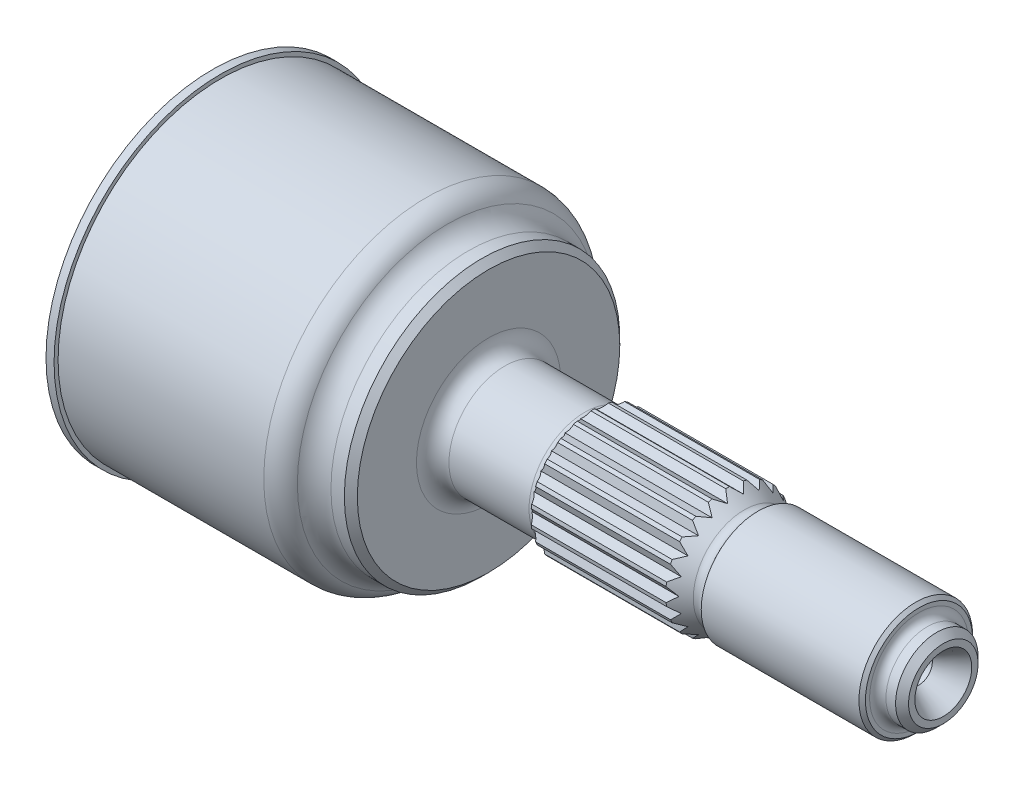
from build123d import *

# Parameters (mm, degrees)
SKETCH2_R          = 18.2245
CENTERPOCKET_DEPTH = 43.942
SKETCH4_R          = 4.7625
HOLES_DEPTH        = 41.275
EXTRUDE3_DEPTH     = 43.942
EXTRUDE4_REACH     = 88.12


with BuildPart() as part:
    # Sketch1 → ProfileRevolve (revolve)
    with BuildSketch(Plane(origin=(0, 0, 0), x_dir=(1, 0, 0), z_dir=(0, 1, 0))):
        with BuildLine():
            Line((0, 0), (0, 32.5374))
            Line((0, 32.5374), (1.5748, 32.5374))
            Line((1.5748, 32.5374), (1.5748, 31.75))
            Line((1.5748, 31.75), (41.783, 31.75))
            ThreePointArc((41.783, 31.75), (44.184517614, 31.102958473), (45.9359, 29.337))
            ThreePointArc((45.9359, 29.337), (47.687282386, 27.571041527), (50.0888, 26.924))
            Line((50.0888, 26.924), (52.705, 26.924))
            Line((52.705, 26.924), (53.975, 25.654))
            Line((53.975, 25.654), (53.975, 14.097))
            ThreePointArc((53.975, 14.097), (54.90493597, 11.85193597), (57.15, 10.922))
            Line((57.15, 10.922), (72.7964, 10.922))
            ThreePointArc((72.7964, 10.922), (73.768510133, 11.251120958), (74.340742977, 12.1031))
            Line((74.340742977, 12.1031), (100.711, 12.1031))
            Line((100.711, 12.1031), (103.979668616, 9.980401781))
            ThreePointArc((103.979668616, 9.980401781), (105.152184528, 9.750803676), (106.156907204, 10.397364731))
            Line((106.156907204, 10.397364731), (106.663571855, 11.1125))
            Line((106.663571855, 11.1125), (137.4902, 11.1125))
            Line((137.4902, 11.1125), (138.1252, 10.4775))
            Line((138.1252, 10.4775), (138.1252, 9.6647))
            ThreePointArc((138.1252, 9.6647), (138.593887729, 8.533187729), (139.7254, 8.0645))
            Line((139.7254, 8.0645), (141.605, 8.0645))
            Line((141.605, 8.0645), (142.875, 6.7945))
            Line((142.875, 6.7945), (142.875, 5.5626))
            Line((142.875, 5.5626), (138.1252, 2.60985))
            Line((138.1252, 2.60985), (134.3152, 2.60985))
            Line((134.3152, 2.60985), (132.554833947, 0))
            Line((132.554833947, 0), (0, 0))
        make_face()
    revolve(axis=Axis((-31.288090642, 0, 0), (1, 0, 0)))

    # Sketch2 → CenterPocket (cut)
    with BuildSketch(Plane.ZY):
        Circle(SKETCH2_R)
    extrude(amount=-CENTERPOCKET_DEPTH, mode=Mode.SUBTRACT)

    # Sketch4 → Holes (cut)
    with BuildSketch(Plane.ZY):
        with Locations((0, 24.638)):
            Circle(SKETCH4_R)
        with Locations((21.337133898, -12.319)):
            Circle(SKETCH4_R)
        with Locations((-21.337133898, -12.319)):
            Circle(SKETCH4_R)
    extrude(amount=-HOLES_DEPTH, mode=Mode.SUBTRACT)

    # Sketch5 → Extrude3 (cut)
    with BuildSketch(Plane.ZY):
        with BuildLine():
            ThreePointArc((-9.942949006, -27.195361756), (0, -28.956), (9.942949006, -27.195361756))
            ThreePointArc((9.942949006, -27.195361756), (11.025002375, -26.528967148), (11.759053938, -25.491619775))
            ThreePointArc((11.759053938, -25.491619775), (0, -7.47395), (-11.759053938, -25.491619775))
            ThreePointArc((-11.759053938, -25.491619775), (-11.025002375, -26.528967148), (-9.942949006, -27.195361756))
        make_face()
        with BuildLine():
            ThreePointArc((-27.955917277, 2.562170453), (-6.472630567, 3.736975), (-16.19686334, 22.929449322))
            ThreePointArc((-16.19686334, 22.929449322), (-17.462258298, 22.812415708), (-18.580399643, 22.208527306))
            ThreePointArc((-18.580399643, 22.208527306), (-25.076631592, 14.478), (-28.523348649, 4.98683445))
            ThreePointArc((-28.523348649, 4.98683445), (-28.487260674, 3.71655144), (-27.955917277, 2.562170453))
        make_face()
        with BuildLine():
            ThreePointArc((16.19686334, 22.929449322), (6.472630567, 3.736975), (27.955917277, 2.562170453))
            ThreePointArc((27.955917277, 2.562170453), (28.487260674, 3.71655144), (28.523348649, 4.98683445))
            ThreePointArc((28.523348649, 4.98683445), (25.076631592, 14.478), (18.580399643, 22.208527306))
            ThreePointArc((18.580399643, 22.208527306), (17.462258298, 22.812415708), (16.19686334, 22.929449322))
        make_face()
    extrude(amount=-EXTRUDE3_DEPTH, mode=Mode.SUBTRACT)

    # Sketch6 → Cut-Revolve1 (revolve, cut)
    with BuildSketch(Plane.XY):
        with BuildLine():
            Line((43.922024716, 18.2245), (2.915575284, 18.2245))
            ThreePointArc((2.915575284, 18.2245), (-2.222563891, 9.748593837), (-4.0132, 0))
            Line((-4.0132, 0), (50.8508, 0))
            ThreePointArc((50.8508, 0), (49.060163891, 9.748593837), (43.922024716, 18.2245))
        make_face()
    revolve(axis=Axis((-21.439153355, 0, 0), (1, 0, 0)), mode=Mode.SUBTRACT)

    # Sketch7 → Extrude4 (cut, up to next)
    with BuildSketch(Plane(origin=(72.7964, 0, 0), x_dir=(0, 0, -1), z_dir=(1, 0, 0)), mode=Mode.PRIVATE) as extrude4_sk1:
        with BuildLine():
            Line((0.368569215, 12.097486778), (1.577126308, 10.969154412))
            Line((1.577126308, 10.969154412), (3.054616309, 11.711291509))
            ThreePointArc((3.054616309, 11.711291509), (1.722450719, 11.979907893), (0.368569215, 12.097486778))
        make_face()
    extrude4_tool1 = extrude(extrude4_sk1.sketch, amount=EXTRUDE4_REACH, mode=Mode.PRIVATE) & part.part
    # Sketch7 → Extrude4 (cut, up to next)
    with BuildSketch(Plane(origin=(72.7964, 0, 0), x_dir=(0, 0, -1), z_dir=(1, 0, 0)), mode=Mode.PRIVATE) as extrude4_sk2:
        with BuildLine():
            Line((3.761895454, 11.503615615), (4.60360953, 10.080498758))
            Line((4.60360953, 10.080498758), (6.230334986, 10.376317052))
            ThreePointArc((6.230334986, 10.376317052), (5.027809444, 11.009367003), (3.761895454, 11.503615615))
        make_face()
    extrude4_tool2 = extrude(extrude4_sk2.sketch, amount=EXTRUDE4_REACH, mode=Mode.PRIVATE) & part.part
    # Sketch7 → Extrude4 (cut, up to next)
    with BuildSketch(Plane(origin=(72.7964, 0, 0), x_dir=(0, 0, -1), z_dir=(1, 0, 0)), mode=Mode.PRIVATE) as extrude4_sk3:
        with BuildLine():
            Line((6.850455295, 9.977789929), (7.257135686, 8.375181045))
            Line((7.257135686, 8.375181045), (8.901308976, 8.200715098))
            ThreePointArc((8.901308976, 8.200715098), (7.925844949, 9.146912673), (6.850455295, 9.977789929))
        make_face()
    extrude4_tool3 = extrude(extrude4_sk3.sketch, amount=EXTRUDE4_REACH, mode=Mode.PRIVATE) & part.part
    # Sketch7 → Extrude4 (cut, up to next)
    with BuildSketch(Plane(origin=(72.7964, 0, 0), x_dir=(0, 0, -1), z_dir=(1, 0, 0)), mode=Mode.PRIVATE) as extrude4_sk4:
        with BuildLine():
            Line((9.38403199, 7.643623043), (9.322731869, 5.991355973))
            Line((9.322731869, 5.991355973), (10.851151851, 5.360739978))
            ThreePointArc((10.851151851, 5.360739978), (10.181775633, 6.543429878), (9.38403199, 7.643623043))
        make_face()
    extrude4_tool4 = extrude(extrude4_sk4.sketch, amount=EXTRUDE4_REACH, mode=Mode.PRIVATE) & part.part
    # Sketch7 → Extrude4 (cut, up to next)
    with BuildSketch(Plane(origin=(72.7964, 0, 0), x_dir=(0, 0, -1), z_dir=(1, 0, 0)), mode=Mode.PRIVATE) as extrude4_sk5:
        with BuildLine():
            Line((11.157370222, 4.690215277), (10.633055761, 3.122146872))
            Line((10.633055761, 3.122146872), (11.921898937, 2.086469586))
            ThreePointArc((11.921898937, 2.086469586), (11.612839409, 3.409837309), (11.157370222, 4.690215277))
        make_face()
    extrude4_tool5 = extrude(extrude4_sk5.sketch, amount=EXTRUDE4_REACH, mode=Mode.PRIVATE) & part.part
    # Sketch7 → Extrude4 (cut, up to next)
    with BuildSketch(Plane(origin=(72.7964, 0, 0), x_dir=(0, 0, -1), z_dir=(1, 0, 0)), mode=Mode.PRIVATE) as extrude4_sk6:
        with BuildLine():
            Line((12.026804674, 1.356834162), (11.081952712, 0))
            Line((11.081952712, 0), (12.026804674, -1.356834162))
            ThreePointArc((12.026804674, -1.356834162), (12.1031, 0), (12.026804674, 1.356834162))
        make_face()
    extrude4_tool6 = extrude(extrude4_sk6.sketch, amount=EXTRUDE4_REACH, mode=Mode.PRIVATE) & part.part
    # Sketch7 → Extrude4 (cut, up to next)
    with BuildSketch(Plane(origin=(72.7964, 0, 0), x_dir=(0, 0, -1), z_dir=(1, 0, 0)), mode=Mode.PRIVATE) as extrude4_sk7:
        with BuildLine():
            Line((11.921898937, -2.086469586), (10.633055761, -3.122146872))
            Line((10.633055761, -3.122146872), (11.157370222, -4.690215277))
            ThreePointArc((11.157370222, -4.690215277), (11.612839409, -3.409837309), (11.921898937, -2.086469586))
        make_face()
    extrude4_tool7 = extrude(extrude4_sk7.sketch, amount=EXTRUDE4_REACH, mode=Mode.PRIVATE) & part.part
    # Sketch7 → Extrude4 (cut, up to next)
    with BuildSketch(Plane(origin=(72.7964, 0, 0), x_dir=(0, 0, -1), z_dir=(1, 0, 0)), mode=Mode.PRIVATE) as extrude4_sk8:
        with BuildLine():
            Line((10.851151851, -5.360739978), (9.322731869, -5.991355973))
            Line((9.322731869, -5.991355973), (9.38403199, -7.643623043))
            ThreePointArc((9.38403199, -7.643623043), (10.181775633, -6.543429878), (10.851151851, -5.360739978))
        make_face()
    extrude4_tool8 = extrude(extrude4_sk8.sketch, amount=EXTRUDE4_REACH, mode=Mode.PRIVATE) & part.part
    # Sketch7 → Extrude4 (cut, up to next)
    with BuildSketch(Plane(origin=(72.7964, 0, 0), x_dir=(0, 0, -1), z_dir=(1, 0, 0)), mode=Mode.PRIVATE) as extrude4_sk9:
        with BuildLine():
            Line((8.901308976, -8.200715098), (7.257135686, -8.375181045))
            Line((7.257135686, -8.375181045), (6.850455295, -9.977789929))
            ThreePointArc((6.850455295, -9.977789929), (7.925844949, -9.146912673), (8.901308976, -8.200715098))
        make_face()
    extrude4_tool9 = extrude(extrude4_sk9.sketch, amount=EXTRUDE4_REACH, mode=Mode.PRIVATE) & part.part
    # Sketch7 → Extrude4 (cut, up to next)
    with BuildSketch(Plane(origin=(72.7964, 0, 0), x_dir=(0, 0, -1), z_dir=(1, 0, 0)), mode=Mode.PRIVATE) as extrude4_sk10:
        with BuildLine():
            Line((6.230334986, -10.376317052), (4.60360953, -10.080498758))
            Line((4.60360953, -10.080498758), (3.761895454, -11.503615615))
            ThreePointArc((3.761895454, -11.503615615), (5.027809444, -11.009367003), (6.230334986, -10.376317052))
        make_face()
    extrude4_tool10 = extrude(extrude4_sk10.sketch, amount=EXTRUDE4_REACH, mode=Mode.PRIVATE) & part.part
    # Sketch7 → Extrude4 (cut, up to next)
    with BuildSketch(Plane(origin=(72.7964, 0, 0), x_dir=(0, 0, -1), z_dir=(1, 0, 0)), mode=Mode.PRIVATE) as extrude4_sk11:
        with BuildLine():
            Line((3.054616309, -11.711291509), (1.577126308, -10.969154412))
            Line((1.577126308, -10.969154412), (0.368569215, -12.097486778))
            ThreePointArc((0.368569215, -12.097486778), (1.722450719, -11.979907893), (3.054616309, -11.711291509))
        make_face()
    extrude4_tool11 = extrude(extrude4_sk11.sketch, amount=EXTRUDE4_REACH, mode=Mode.PRIVATE) & part.part
    # Sketch7 → Extrude4 (cut, up to next)
    with BuildSketch(Plane(origin=(72.7964, 0, 0), x_dir=(0, 0, -1), z_dir=(1, 0, 0)), mode=Mode.PRIVATE) as extrude4_sk12:
        with BuildLine():
            Line((-0.368569215, -12.097486778), (-1.577126308, -10.969154412))
            Line((-1.577126308, -10.969154412), (-3.054616309, -11.711291509))
            ThreePointArc((-3.054616309, -11.711291509), (-1.722450719, -11.979907893), (-0.368569215, -12.097486778))
        make_face()
    extrude4_tool12 = extrude(extrude4_sk12.sketch, amount=EXTRUDE4_REACH, mode=Mode.PRIVATE) & part.part
    # Sketch7 → Extrude4 (cut, up to next)
    with BuildSketch(Plane(origin=(72.7964, 0, 0), x_dir=(0, 0, -1), z_dir=(1, 0, 0)), mode=Mode.PRIVATE) as extrude4_sk13:
        with BuildLine():
            Line((-3.761895454, -11.503615615), (-4.60360953, -10.080498758))
            Line((-4.60360953, -10.080498758), (-6.230334986, -10.376317052))
            ThreePointArc((-6.230334986, -10.376317052), (-5.027809444, -11.009367003), (-3.761895454, -11.503615615))
        make_face()
    extrude4_tool13 = extrude(extrude4_sk13.sketch, amount=EXTRUDE4_REACH, mode=Mode.PRIVATE) & part.part
    # Sketch7 → Extrude4 (cut, up to next)
    with BuildSketch(Plane(origin=(72.7964, 0, 0), x_dir=(0, 0, -1), z_dir=(1, 0, 0)), mode=Mode.PRIVATE) as extrude4_sk14:
        with BuildLine():
            Line((-6.850455295, -9.977789929), (-7.257135686, -8.375181045))
            Line((-7.257135686, -8.375181045), (-8.901308976, -8.200715098))
            ThreePointArc((-8.901308976, -8.200715098), (-7.925844949, -9.146912673), (-6.850455295, -9.977789929))
        make_face()
    extrude4_tool14 = extrude(extrude4_sk14.sketch, amount=EXTRUDE4_REACH, mode=Mode.PRIVATE) & part.part
    # Sketch7 → Extrude4 (cut, up to next)
    with BuildSketch(Plane(origin=(72.7964, 0, 0), x_dir=(0, 0, -1), z_dir=(1, 0, 0)), mode=Mode.PRIVATE) as extrude4_sk15:
        with BuildLine():
            Line((-9.38403199, -7.643623043), (-9.322731869, -5.991355973))
            Line((-9.322731869, -5.991355973), (-10.851151851, -5.360739978))
            ThreePointArc((-10.851151851, -5.360739978), (-10.181775633, -6.543429878), (-9.38403199, -7.643623043))
        make_face()
    extrude4_tool15 = extrude(extrude4_sk15.sketch, amount=EXTRUDE4_REACH, mode=Mode.PRIVATE) & part.part
    # Sketch7 → Extrude4 (cut, up to next)
    with BuildSketch(Plane(origin=(72.7964, 0, 0), x_dir=(0, 0, -1), z_dir=(1, 0, 0)), mode=Mode.PRIVATE) as extrude4_sk16:
        with BuildLine():
            Line((-11.157370222, -4.690215277), (-10.633055761, -3.122146872))
            Line((-10.633055761, -3.122146872), (-11.921898937, -2.086469586))
            ThreePointArc((-11.921898937, -2.086469586), (-11.612839409, -3.409837309), (-11.157370222, -4.690215277))
        make_face()
    extrude4_tool16 = extrude(extrude4_sk16.sketch, amount=EXTRUDE4_REACH, mode=Mode.PRIVATE) & part.part
    # Sketch7 → Extrude4 (cut, up to next)
    with BuildSketch(Plane(origin=(72.7964, 0, 0), x_dir=(0, 0, -1), z_dir=(1, 0, 0)), mode=Mode.PRIVATE) as extrude4_sk17:
        with BuildLine():
            Line((-12.026804674, -1.356834162), (-11.081952712, 0))
            Line((-11.081952712, 0), (-12.026804674, 1.356834162))
            ThreePointArc((-12.026804674, 1.356834162), (-12.1031, 0), (-12.026804674, -1.356834162))
        make_face()
    extrude4_tool17 = extrude(extrude4_sk17.sketch, amount=EXTRUDE4_REACH, mode=Mode.PRIVATE) & part.part
    # Sketch7 → Extrude4 (cut, up to next)
    with BuildSketch(Plane(origin=(72.7964, 0, 0), x_dir=(0, 0, -1), z_dir=(1, 0, 0)), mode=Mode.PRIVATE) as extrude4_sk18:
        with BuildLine():
            Line((-11.921898937, 2.086469586), (-10.633055761, 3.122146872))
            Line((-10.633055761, 3.122146872), (-11.157370222, 4.690215277))
            ThreePointArc((-11.157370222, 4.690215277), (-11.612839409, 3.409837309), (-11.921898937, 2.086469586))
        make_face()
    extrude4_tool18 = extrude(extrude4_sk18.sketch, amount=EXTRUDE4_REACH, mode=Mode.PRIVATE) & part.part
    # Sketch7 → Extrude4 (cut, up to next)
    with BuildSketch(Plane(origin=(72.7964, 0, 0), x_dir=(0, 0, -1), z_dir=(1, 0, 0)), mode=Mode.PRIVATE) as extrude4_sk19:
        with BuildLine():
            Line((-10.851151851, 5.360739978), (-9.322731869, 5.991355973))
            Line((-9.322731869, 5.991355973), (-9.38403199, 7.643623043))
            ThreePointArc((-9.38403199, 7.643623043), (-10.181775633, 6.543429878), (-10.851151851, 5.360739978))
        make_face()
    extrude4_tool19 = extrude(extrude4_sk19.sketch, amount=EXTRUDE4_REACH, mode=Mode.PRIVATE) & part.part
    # Sketch7 → Extrude4 (cut, up to next)
    with BuildSketch(Plane(origin=(72.7964, 0, 0), x_dir=(0, 0, -1), z_dir=(1, 0, 0)), mode=Mode.PRIVATE) as extrude4_sk20:
        with BuildLine():
            Line((-8.901308976, 8.200715098), (-7.257135686, 8.375181045))
            Line((-7.257135686, 8.375181045), (-6.850455295, 9.977789929))
            ThreePointArc((-6.850455295, 9.977789929), (-7.925844949, 9.146912673), (-8.901308976, 8.200715098))
        make_face()
    extrude4_tool20 = extrude(extrude4_sk20.sketch, amount=EXTRUDE4_REACH, mode=Mode.PRIVATE) & part.part
    # Sketch7 → Extrude4 (cut, up to next)
    with BuildSketch(Plane(origin=(72.7964, 0, 0), x_dir=(0, 0, -1), z_dir=(1, 0, 0)), mode=Mode.PRIVATE) as extrude4_sk21:
        with BuildLine():
            Line((-6.230334986, 10.376317052), (-4.60360953, 10.080498758))
            Line((-4.60360953, 10.080498758), (-3.761895454, 11.503615615))
            ThreePointArc((-3.761895454, 11.503615615), (-5.027809444, 11.009367003), (-6.230334986, 10.376317052))
        make_face()
    extrude4_tool21 = extrude(extrude4_sk21.sketch, amount=EXTRUDE4_REACH, mode=Mode.PRIVATE) & part.part
    # Sketch7 → Extrude4 (cut, up to next)
    with BuildSketch(Plane(origin=(72.7964, 0, 0), x_dir=(0, 0, -1), z_dir=(1, 0, 0)), mode=Mode.PRIVATE) as extrude4_sk22:
        with BuildLine():
            Line((-3.054616309, 11.711291509), (-1.577126308, 10.969154412))
            Line((-1.577126308, 10.969154412), (-0.368569215, 12.097486778))
            ThreePointArc((-0.368569215, 12.097486778), (-1.722450719, 11.979907893), (-3.054616309, 11.711291509))
        make_face()
    extrude4_tool22 = extrude(extrude4_sk22.sketch, amount=EXTRUDE4_REACH, mode=Mode.PRIVATE) & part.part
    add(extrude4_tool1.solids().sort_by_distance((72.7964, 11.625902, -1.671552))[0], mode=Mode.SUBTRACT)
    add(extrude4_tool2.solids().sort_by_distance((72.7964, 10.68404, -4.879238))[0], mode=Mode.SUBTRACT)
    add(extrude4_tool3.solids().sort_by_distance((72.7964, 8.876621, -7.691636))[0], mode=Mode.SUBTRACT)
    add(extrude4_tool4.solids().sort_by_distance((72.7964, 6.350072, -9.880904))[0], mode=Mode.SUBTRACT)
    add(extrude4_tool5.solids().sort_by_distance((72.7964, 3.309077, -11.26968))[0], mode=Mode.SUBTRACT)
    add(extrude4_tool6.solids().sort_by_distance((72.7964, 0, -11.745453))[0], mode=Mode.SUBTRACT)
    add(extrude4_tool7.solids().sort_by_distance((72.7964, -3.309077, -11.26968))[0], mode=Mode.SUBTRACT)
    add(extrude4_tool8.solids().sort_by_distance((72.7964, -6.350072, -9.880904))[0], mode=Mode.SUBTRACT)
    add(extrude4_tool9.solids().sort_by_distance((72.7964, -8.876621, -7.691636))[0], mode=Mode.SUBTRACT)
    add(extrude4_tool10.solids().sort_by_distance((72.7964, -10.68404, -4.879238))[0], mode=Mode.SUBTRACT)
    add(extrude4_tool11.solids().sort_by_distance((72.7964, -11.625902, -1.671552))[0], mode=Mode.SUBTRACT)
    add(extrude4_tool12.solids().sort_by_distance((72.7964, -11.625902, 1.671552))[0], mode=Mode.SUBTRACT)
    add(extrude4_tool13.solids().sort_by_distance((72.7964, -10.68404, 4.879238))[0], mode=Mode.SUBTRACT)
    add(extrude4_tool14.solids().sort_by_distance((72.7964, -8.876621, 7.691636))[0], mode=Mode.SUBTRACT)
    add(extrude4_tool15.solids().sort_by_distance((72.7964, -6.350072, 9.880904))[0], mode=Mode.SUBTRACT)
    add(extrude4_tool16.solids().sort_by_distance((72.7964, -3.309077, 11.26968))[0], mode=Mode.SUBTRACT)
    add(extrude4_tool17.solids().sort_by_distance((72.7964, 0, 11.745453))[0], mode=Mode.SUBTRACT)
    add(extrude4_tool18.solids().sort_by_distance((72.7964, 3.309077, 11.26968))[0], mode=Mode.SUBTRACT)
    add(extrude4_tool19.solids().sort_by_distance((72.7964, 6.350072, 9.880904))[0], mode=Mode.SUBTRACT)
    add(extrude4_tool20.solids().sort_by_distance((72.7964, 8.876621, 7.691636))[0], mode=Mode.SUBTRACT)
    add(extrude4_tool21.solids().sort_by_distance((72.7964, 10.68404, 4.879238))[0], mode=Mode.SUBTRACT)
    add(extrude4_tool22.solids().sort_by_distance((72.7964, 11.625902, 1.671552))[0], mode=Mode.SUBTRACT)


solid = part.part
